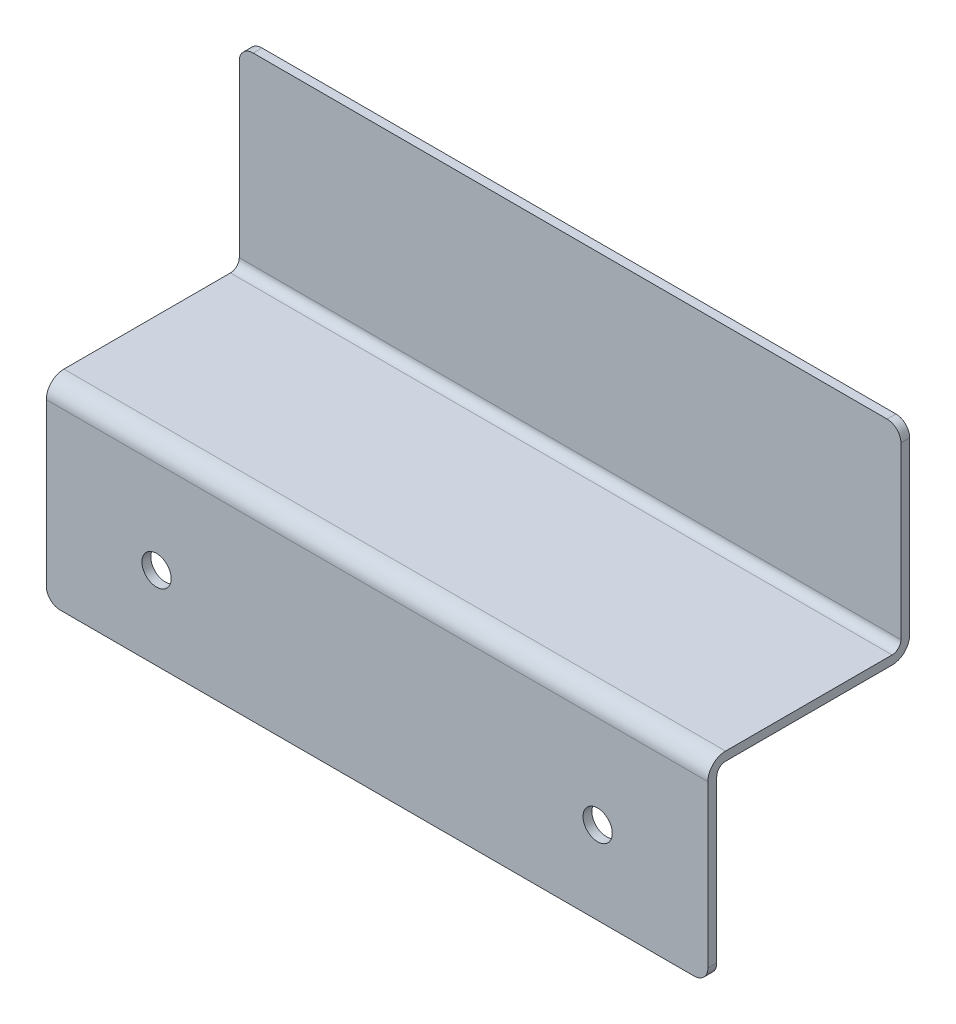
from build123d import *

# Parameters (mm, degrees)
BOSS_EXTRUDE1_DEPTH = 152.4
FILLET1_R           = 2.032
FILLET2_R           = 4.064
FILLET3_R           = 3.175
SKETCH2_R           = 3.3655
CUT_EXTRUDE1_DEPTH  = 47.482


with BuildPart() as part:
    # Sketch1 → Boss-Extrude1 (new body)
    with BuildSketch(Plane(origin=(0, 0, 0), x_dir=(0, 0, -1), z_dir=(1, 0, 0))):
        Polygon((0, 0), (0, -44.45), (-44.45, -44.45), (-44.45, -88.9), (-42.418, -88.9), (-42.418, -46.482), (2.032, -46.482), (2.032, 0), align=None)
    extrude(amount=BOSS_EXTRUDE1_DEPTH)

    # Fillet1
    fillet1_edges = [part.edges().sort_by_distance(p)[0] for p in [
        (76.2, -46.482, 42.418),
        (76.2, -44.45, 0),
    ]]
    fillet(fillet1_edges, radius=FILLET1_R)

    # Fillet2
    fillet2_edges = [part.edges().sort_by_distance(p)[0] for p in [
        (76.2, -46.482, -2.032),
        (76.2, -44.45, 44.45),
    ]]
    fillet(fillet2_edges, radius=FILLET2_R)

    # Fillet3
    fillet3_edges = [part.edges().sort_by_distance(p)[0] for p in [
        (0, 0, -1.016),
        (152.4, -88.9, 43.434),
        (152.4, 0, -1.016),
        (0, -88.9, 43.434),
    ]]
    fillet(fillet3_edges, radius=FILLET3_R)

    # Sketch2 → Cut-Extrude1 (cut, through all)
    with BuildSketch(Plane.XY.offset(44.45)):
        with Locations((25.4, -69.85)):
            Circle(SKETCH2_R)
        with Locations((127, -69.85)):
            Circle(SKETCH2_R)
    extrude(amount=-CUT_EXTRUDE1_DEPTH, mode=Mode.SUBTRACT)


solid = part.part
